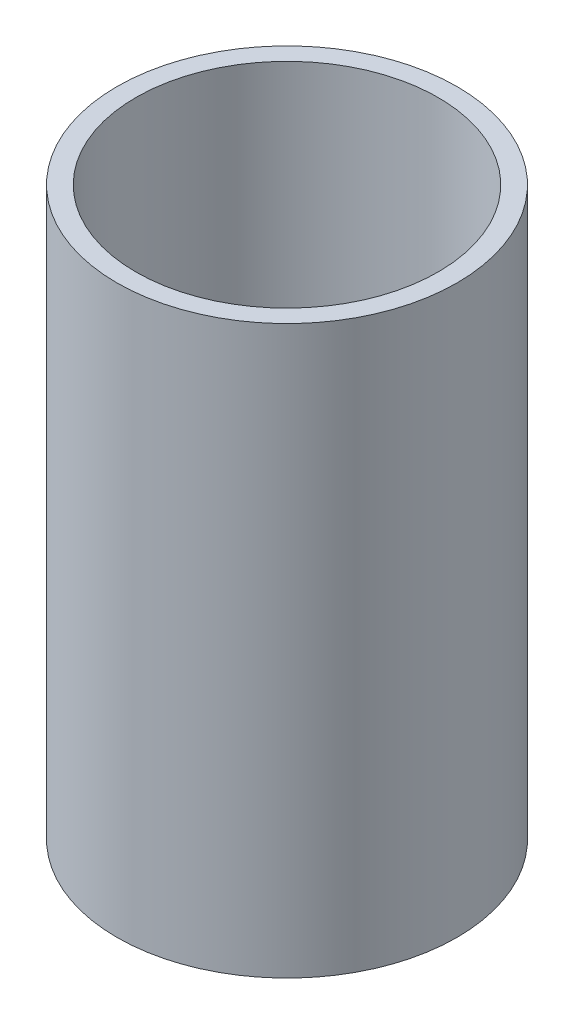
from build123d import *

# Parameters (mm, degrees)
SKETCH1_R           = 28.575
BOSS_EXTRUDE1_DEPTH = 3.175
SKETCH2_R           = 28.575
SKETCH2_R_2         = 25.4
BOSS_EXTRUDE2_DEPTH = 92.075


with BuildPart() as part:
    # Sketch1 → Boss-Extrude1 (new body)
    with BuildSketch(Plane(origin=(0, 0, 0), x_dir=(1, 0, 0), z_dir=(0, 1, 0))):
        Circle(SKETCH1_R)
    extrude(amount=BOSS_EXTRUDE1_DEPTH)

    # Sketch2 → Boss-Extrude2 (add)
    with BuildSketch(Plane(origin=(0, 3.175, 0), x_dir=(1, 0, 0), z_dir=(0, 1, 0))):
        Circle(SKETCH2_R)
        Circle(SKETCH2_R_2, mode=Mode.SUBTRACT)
    extrude(amount=BOSS_EXTRUDE2_DEPTH)


solid = part.part
